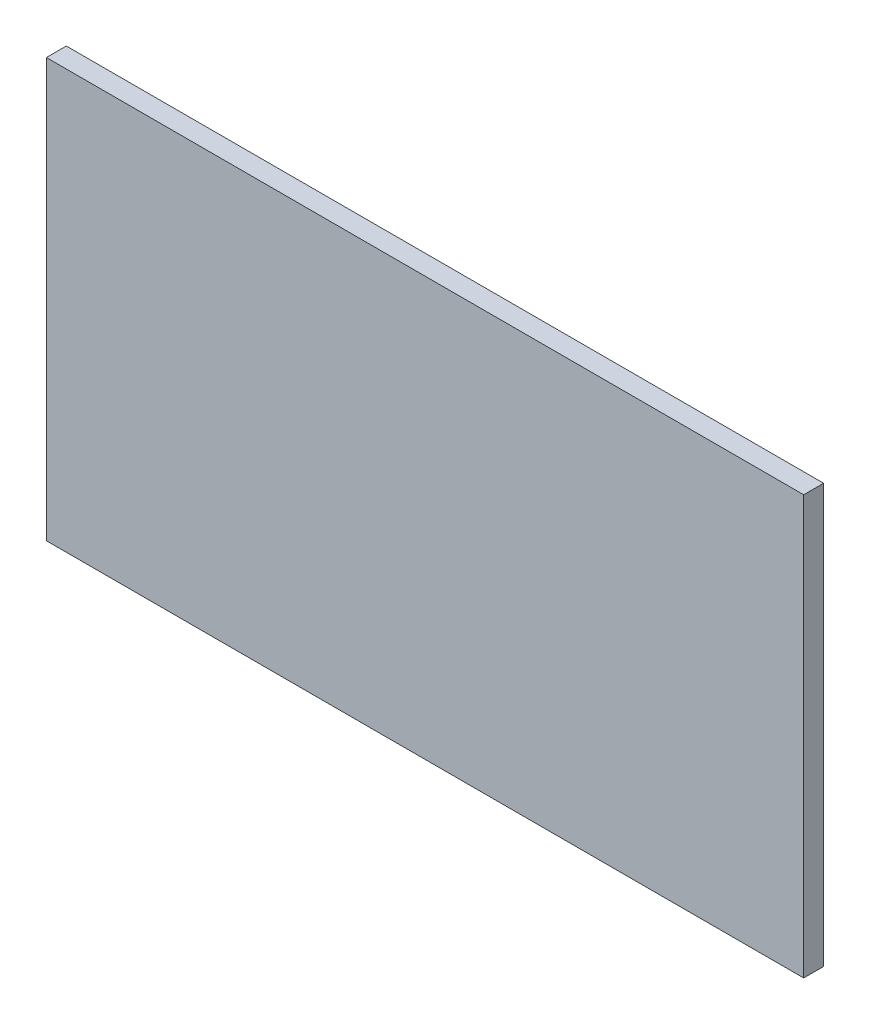
from build123d import *

# Parameters (mm, degrees)
ESQUISSE1_W        = 380
ESQUISSE1_H        = 210
BOSS_EXTRU_1_DEPTH = 10


with BuildPart() as part:
    # Esquisse1 → Boss.-Extru.1 (new body)
    with BuildSketch(Plane.XY):
        Rectangle(ESQUISSE1_W, ESQUISSE1_H)
    extrude(amount=BOSS_EXTRU_1_DEPTH)


solid = part.part
